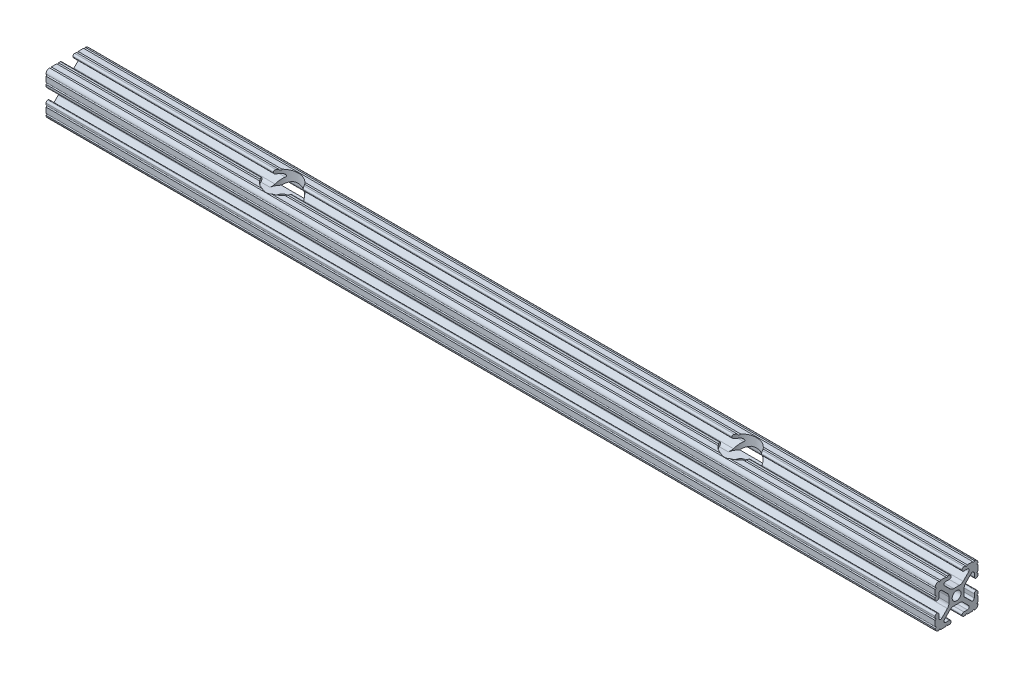
from build123d import *

# Parameters (mm, degrees)
SKETCH1_R                                           = 2.6035
BOSS_EXTRUDE1_DEPTH                                 = 263.525
CBORE_FOR_0_BINDING_HEAD_MACHINE_SCREW1_D           = 6.35
CBORE_FOR_0_BINDING_HEAD_MACHINE_SCREW1_CBORE_D     = 19.05
CBORE_FOR_0_BINDING_HEAD_MACHINE_SCREW1_CBORE_DEPTH = 8.2042


with BuildPart() as part:
    # Sketch1 → Boss-Extrude1 (new body, symmetric)
    with BuildSketch(Plane(origin=(0, 0, 0), x_dir=(0, 0, -1), z_dir=(1, 0, 0))):
        with BuildLine():
            Line((6.333126718, -12.7), (9.550443118, -12.7))
            ThreePointArc((9.550443118, -12.7), (10.058366869, -12.192000006), (10.566443095, -12.699847501))
            ThreePointArc((10.566443095, -12.699847501), (12.082537762, -12.08250727), (12.699846982, -10.566399977))
            ThreePointArc((12.699846982, -10.566399977), (12.192000006, -10.058323491), (12.7, -9.5504))
            Line((12.7, -9.5504), (12.7, -6.3330836))
            ThreePointArc((12.7, -6.3330836), (12.192, -5.8250836), (12.7, -5.3170836))
            Line((12.7, -5.3170836), (12.7, -4.287469289))
            ThreePointArc((12.7, -4.287469289), (12.39275138, -3.545705502), (11.650987593, -3.238456882))
            Line((11.650987593, -3.238456882), (11.539212407, -3.238456882))
            ThreePointArc((11.539212407, -3.238456882), (10.79744862, -3.545705502), (10.4902, -4.287469289))
            Line((10.4902, -4.287469289), (10.4902, -6.402089023))
            ThreePointArc((10.4902, -6.402089023), (9.856505071, -7.351067942), (8.737131347, -7.129408934))
            Line((8.737131347, -7.129408934), (4.5085, -2.9104418))
            Line((4.5085, -2.9104418), (4.5085, 1.593185507))
            ThreePointArc((4.5085, 1.593185507), (4.750877967, 2.809883091), (5.441005833, 3.840816462))
            Line((5.441005833, 3.840816462), (8.737131347, 7.129408934))
            ThreePointArc((8.737131347, 7.129408934), (9.856505071, 7.351067942), (10.4902, 6.402089023))
            Line((10.4902, 6.402089023), (10.4902, 4.287469289))
            ThreePointArc((10.4902, 4.287469289), (10.79744862, 3.545705502), (11.539212407, 3.238456882))
            Line((11.539212407, 3.238456882), (11.650987593, 3.238456882))
            ThreePointArc((11.650987593, 3.238456882), (12.39275138, 3.545705502), (12.7, 4.287469289))
            Line((12.7, 4.287469289), (12.7, 5.3170836))
            ThreePointArc((12.7, 5.3170836), (12.192, 5.8250836), (12.7, 6.3330836))
            Line((12.7, 6.3330836), (12.7, 9.5504))
            ThreePointArc((12.7, 9.5504), (12.192000006, 10.058323491), (12.699846982, 10.566399977))
            ThreePointArc((12.699846982, 10.566399977), (12.082537762, 12.08250727), (10.566443095, 12.699847501))
            ThreePointArc((10.566443095, 12.699847501), (10.058366869, 12.192000006), (9.550443118, 12.7))
            Line((9.550443118, 12.7), (6.333126718, 12.7))
            ThreePointArc((6.333126718, 12.7), (5.825126718, 12.192), (5.317126718, 12.7))
            Line((5.317126718, 12.7), (4.287512407, 12.7))
            ThreePointArc((4.287512407, 12.7), (3.54574862, 12.39275138), (3.2385, 11.650987593))
            Line((3.2385, 11.650987593), (3.2385, 11.539212407))
            ThreePointArc((3.2385, 11.539212407), (3.54574862, 10.79744862), (4.287512407, 10.4902))
            Line((4.287512407, 10.4902), (6.476788598, 10.4902))
            ThreePointArc((6.476788598, 10.4902), (7.432222385, 9.85140422), (7.207036008, 8.724370562))
            Line((7.207036008, 8.724370562), (3.898272566, 5.423169045))
            ThreePointArc((3.898272566, 5.423169045), (2.869120213, 4.736787962), (1.655778399, 4.4958))
            Line((1.655778399, 4.4958), (-1.655778399, 4.4958))
            ThreePointArc((-1.655778399, 4.4958), (-2.869120213, 4.736787962), (-3.898272566, 5.423169045))
            Line((-3.898272566, 5.423169045), (-7.207036008, 8.724370562))
            ThreePointArc((-7.207036008, 8.724370562), (-7.432222385, 9.85140422), (-6.476788598, 10.4902))
            Line((-6.476788598, 10.4902), (-4.287512407, 10.4902))
            ThreePointArc((-4.287512407, 10.4902), (-3.54574862, 10.79744862), (-3.2385, 11.539212407))
            Line((-3.2385, 11.539212407), (-3.2385, 11.650987593))
            ThreePointArc((-3.2385, 11.650987593), (-3.54574862, 12.39275138), (-4.287512407, 12.7))
            Line((-4.287512407, 12.7), (-5.317126718, 12.7))
            ThreePointArc((-5.317126718, 12.7), (-5.825126718, 12.192), (-6.333126718, 12.7))
            Line((-6.333126718, 12.7), (-9.550443118, 12.7))
            ThreePointArc((-9.550443118, 12.7), (-10.058366869, 12.192000006), (-10.566443095, 12.699847501))
            ThreePointArc((-10.566443095, 12.699847501), (-12.082537762, 12.08250727), (-12.699846982, 10.566399977))
            ThreePointArc((-12.699846982, 10.566399977), (-12.192000006, 10.058323491), (-12.7, 9.5504))
            Line((-12.7, 9.5504), (-12.7, 6.3330836))
            ThreePointArc((-12.7, 6.3330836), (-12.192, 5.8250836), (-12.7, 5.3170836))
            Line((-12.7, 5.3170836), (-12.7, 4.287469289))
            ThreePointArc((-12.7, 4.287469289), (-12.39275138, 3.545705502), (-11.650987593, 3.238456882))
            Line((-11.650987593, 3.238456882), (-11.539212407, 3.238456882))
            ThreePointArc((-11.539212407, 3.238456882), (-10.79744862, 3.545705502), (-10.4902, 4.287469289))
            Line((-10.4902, 4.287469289), (-10.4902, 6.402089023))
            ThreePointArc((-10.4902, 6.402089023), (-9.856505071, 7.351067942), (-8.737131347, 7.129408934))
            Line((-8.737131347, 7.129408934), (-5.441005833, 3.840816462))
            ThreePointArc((-5.441005833, 3.840816462), (-4.750877967, 2.809883091), (-4.5085, 1.593185507))
            Line((-4.5085, 1.593185507), (-4.5085, -1.593185507))
            ThreePointArc((-4.5085, -1.593185507), (-4.750877967, -2.809883091), (-5.441005833, -3.840816462))
            Line((-5.441005833, -3.840816462), (-8.737131347, -7.129408934))
            ThreePointArc((-8.737131347, -7.129408934), (-9.856505071, -7.351067942), (-10.4902, -6.402089023))
            Line((-10.4902, -6.402089023), (-10.4902, -4.287469289))
            ThreePointArc((-10.4902, -4.287469289), (-10.79744862, -3.545705502), (-11.539212407, -3.238456882))
            Line((-11.539212407, -3.238456882), (-11.650987593, -3.238456882))
            ThreePointArc((-11.650987593, -3.238456882), (-12.39275138, -3.545705502), (-12.7, -4.287469289))
            Line((-12.7, -4.287469289), (-12.7, -5.3170836))
            ThreePointArc((-12.7, -5.3170836), (-12.192, -5.8250836), (-12.7, -6.3330836))
            Line((-12.7, -6.3330836), (-12.7, -9.5504))
            ThreePointArc((-12.7, -9.5504), (-12.192000006, -10.058323491), (-12.699846982, -10.566399977))
            ThreePointArc((-12.699846982, -10.566399977), (-12.082537762, -12.08250727), (-10.566443095, -12.699847501))
            ThreePointArc((-10.566443095, -12.699847501), (-10.058366869, -12.192000006), (-9.550443118, -12.7))
            Line((-9.550443118, -12.7), (-6.333126718, -12.7))
            ThreePointArc((-6.333126718, -12.7), (-5.825126718, -12.192), (-5.317126718, -12.7))
            Line((-5.317126718, -12.7), (-4.287512407, -12.7))
            ThreePointArc((-4.287512407, -12.7), (-3.54574862, -12.39275138), (-3.2385, -11.650987593))
            Line((-3.2385, -11.650987593), (-3.2385, -11.539212407))
            ThreePointArc((-3.2385, -11.539212407), (-3.54574862, -10.79744862), (-4.287512407, -10.4902))
            Line((-4.287512407, -10.4902), (-6.416408329, -10.4902))
            ThreePointArc((-6.416408329, -10.4902), (-7.41473083, -9.822813117), (-7.179650497, -8.645192506))
            Line((-7.179650497, -8.645192506), (-3.952270251, -5.423690499))
            ThreePointArc((-3.952270251, -5.423690499), (-2.922936451, -4.736929036), (-1.709253557, -4.4958))
            Line((-1.709253557, -4.4958), (1.709253557, -4.4958))
            ThreePointArc((1.709253557, -4.4958), (2.922936451, -4.736929036), (3.952270251, -5.423690499))
            Line((3.952270251, -5.423690499), (7.179650497, -8.645192506))
            ThreePointArc((7.179650497, -8.645192506), (7.41473083, -9.822813117), (6.416408329, -10.4902))
            Line((6.416408329, -10.4902), (4.287512407, -10.4902))
            ThreePointArc((4.287512407, -10.4902), (3.54574862, -10.79744862), (3.2385, -11.539212407))
            Line((3.2385, -11.539212407), (3.2385, -11.650987593))
            ThreePointArc((3.2385, -11.650987593), (3.54574862, -12.39275138), (4.287512407, -12.7))
            Line((4.287512407, -12.7), (5.317126718, -12.7))
            ThreePointArc((5.317126718, -12.7), (5.825126718, -12.192), (6.333126718, -12.7))
        make_face()
        Circle(SKETCH1_R, mode=Mode.SUBTRACT)
    extrude(amount=BOSS_EXTRUDE1_DEPTH, both=True)

    # CBORE for #0 Binding Head Machine Screw1 (through all)
    with Locations(Plane(origin=(0, 12.7, 0), x_dir=(1, 0, 0), z_dir=(0, 1, 0))):
        with Locations((-135.858839885, -0.381), (135.858839885, -0.381)):
            CounterBoreHole(CBORE_FOR_0_BINDING_HEAD_MACHINE_SCREW1_D / 2, CBORE_FOR_0_BINDING_HEAD_MACHINE_SCREW1_CBORE_D / 2, CBORE_FOR_0_BINDING_HEAD_MACHINE_SCREW1_CBORE_DEPTH)


solid = part.part
